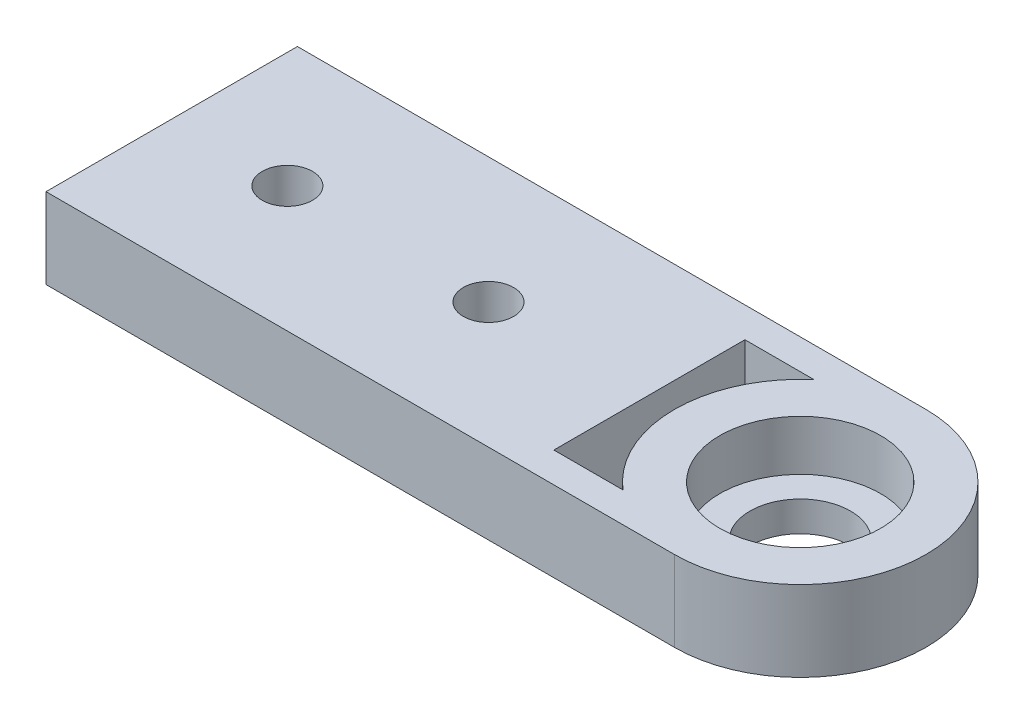
from build123d import *

# Parameters (mm, degrees)
SKETCH1_R           = 5
BOSS_EXTRUDE1_DEPTH = 8
SKETCH2_R           = 8
CUT_EXTRUDE1_DEPTH  = 5
SKETCH3_W           = 25
SKETCH3_H           = 8
BOSS_EXTRUDE2_DEPTH = 15
SKETCH4_R           = 2.5
CUT_EXTRUDE2_DEPTH  = 10


with BuildPart() as part:
    # Sketch1 → Boss-Extrude1 (new body)
    with BuildSketch(Plane(origin=(0, 0, 0), x_dir=(1, 0, 0), z_dir=(0, 1, 0))):
        with BuildLine():
            Line((-16.25, 12.5), (16.25, 12.5))
            Line((16.25, 12.5), (31.25, 12.5))
            ThreePointArc((31.25, 12.5), (43.75, 0), (31.25, -12.5))
            Line((31.25, -12.5), (16.25, -12.5))
            Line((16.25, -12.5), (-16.25, -12.5))
            Line((-16.25, -12.5), (-16.25, 12.5))
        make_face()
        with Locations((31.25, 0)):
            Circle(SKETCH1_R, mode=Mode.SUBTRACT)
        with BuildLine():
            Line((16.25, 9.5), (16.25, -9.5))
            Line((16.25, -9.5), (23.125961595, -9.5))
            ThreePointArc((23.125961595, -9.5), (18.75, 0), (23.125961595, 9.5))
            Line((23.125961595, 9.5), (16.25, 9.5))
        make_face(mode=Mode.SUBTRACT)
    extrude(amount=BOSS_EXTRUDE1_DEPTH)

    # Sketch2 → Cut-Extrude1 (cut)
    with BuildSketch(Plane(origin=(0, 8, 0), x_dir=(1, 0, 0), z_dir=(0, 1, 0))):
        with Locations((31.25, 0)):
            Circle(SKETCH2_R)
    extrude(amount=-CUT_EXTRUDE1_DEPTH, mode=Mode.SUBTRACT)

    # Sketch3 → Boss-Extrude2 (add)
    with BuildSketch(Plane.ZY.offset(16.25)):
        with Locations((0, 4)):
            Rectangle(SKETCH3_W, SKETCH3_H)
    extrude(amount=BOSS_EXTRUDE2_DEPTH)

    # Sketch4 → Cut-Extrude2 (cut)
    with BuildSketch(Plane(origin=(0, 0, 0), x_dir=(-1, 0, 0), z_dir=(0, -1, 0))):
        with Locations((-0.25, 0)):
            Circle(SKETCH4_R)
        with Locations((19.75, 0)):
            Circle(SKETCH4_R)
    extrude(amount=-CUT_EXTRUDE2_DEPTH, mode=Mode.SUBTRACT)


solid = part.part
